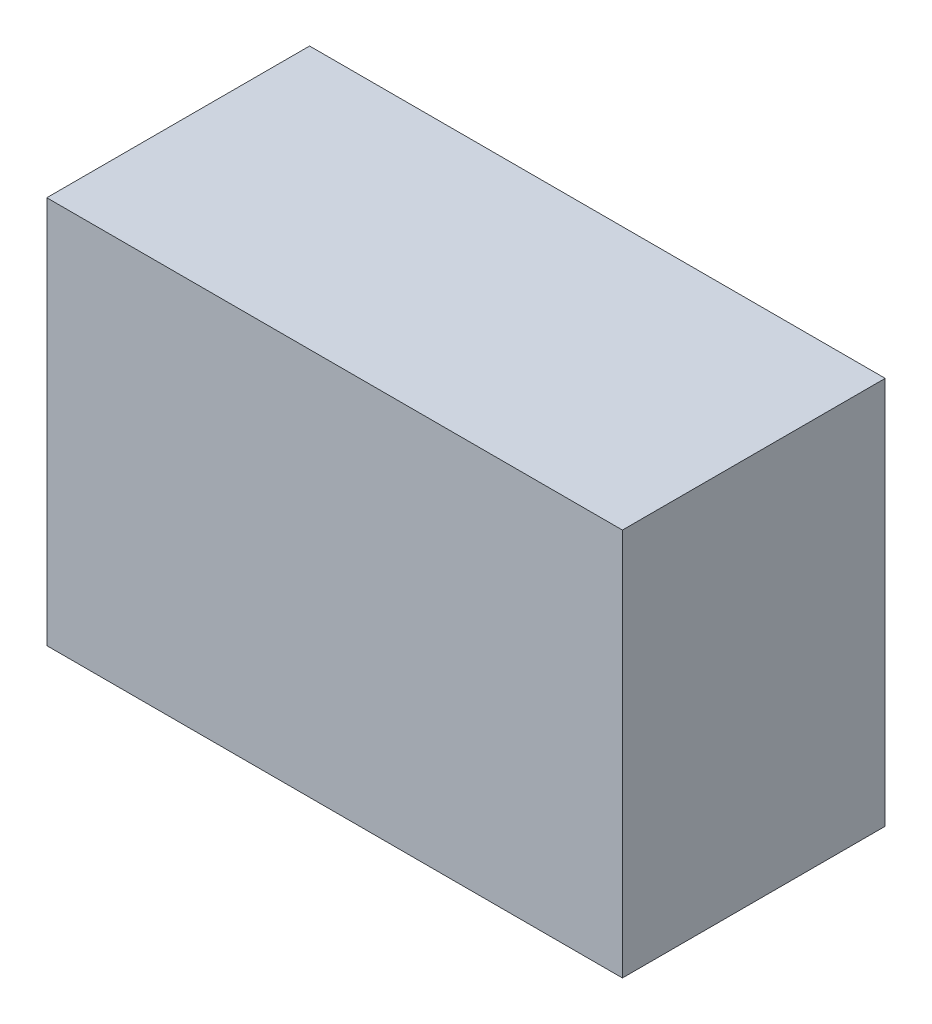
from build123d import *

# Parameters (mm, degrees)
SKETCH_1_W             = 46
SKETCH_1_H             = 31
EXTRUDE_1_DEPTH        = 21
SKETCH_2_R             = 1
EXTRUDE_2_DEPTH        = 5
EXTRUDE_2_DEPTH_BACK   = 5
EXTRUDE_2_2_DEPTH      = 5
EXTRUDE_2_2_DEPTH_BACK = 5


with BuildPart() as part:
    # ｽｹｯﾁ1 → ﾎﾞｽ - 押し出し1 (new body)
    with BuildSketch(Plane.XY):
        with Locations((23, 15.5)):
            Rectangle(SKETCH_1_W, SKETCH_1_H)
    extrude(amount=EXTRUDE_1_DEPTH)


with BuildPart() as body_2:
    # ｽｹｯﾁ2 → ﾎﾞｽ - 押し出し2 (new body, two sides)
    with BuildSketch(Plane.XZ) as extrude_2_sk:
        with Locations((-1, 11.5)):
            Circle(SKETCH_2_R)
    extrude(amount=EXTRUDE_2_DEPTH)
    extrude(extrude_2_sk.sketch, amount=-EXTRUDE_2_DEPTH_BACK)


with BuildPart() as body_3:
    # ｽｹｯﾁ2 → Extrude 2 2 (new body, two sides)
    with BuildSketch(Plane.XZ) as extrude_2_2_sk:
        with Locations((-1, 9.5)):
            Circle(SKETCH_2_R)
    extrude(amount=EXTRUDE_2_2_DEPTH)
    extrude(extrude_2_2_sk.sketch, amount=-EXTRUDE_2_2_DEPTH_BACK)


solid = Compound([part.part, body_2.part, body_3.part])
